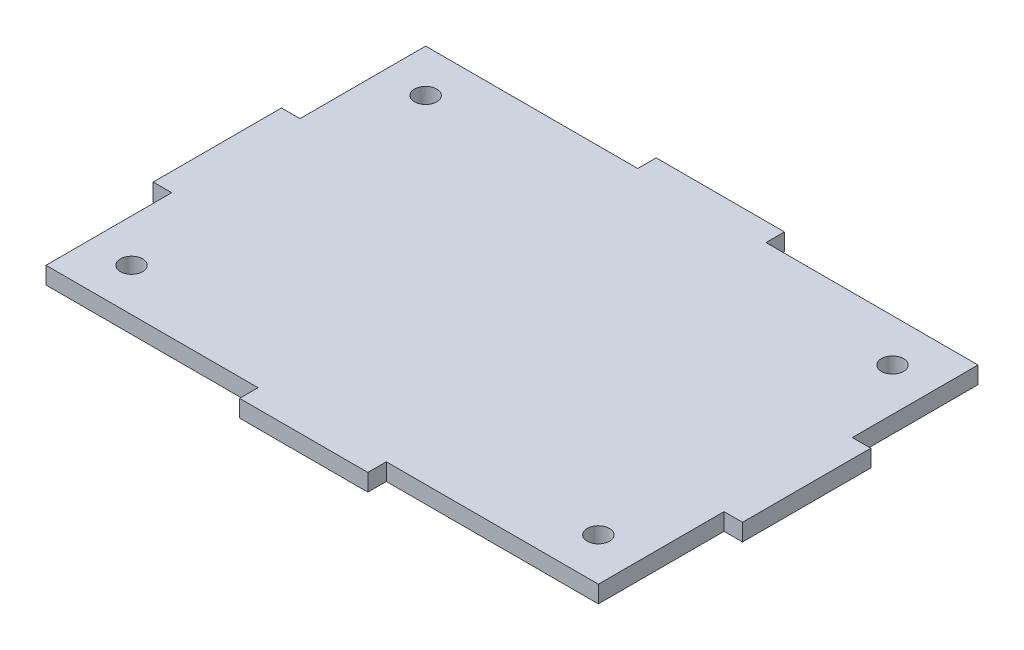
from build123d import *

# Parameters (mm, degrees)
SKETCH1_W           = 82.042
SKETCH1_H           = 56.388
SKETCH1_R           = 1.651
BOSS_EXTRUDE1_DEPTH = 2.54
SKETCH2_W           = 19.05
SKETCH2_H           = 2.7432
SKETCH2_W_2         = 2.7432
SKETCH2_H_2         = 19.05
BOSS_EXTRUDE2_DEPTH = 2.54


with BuildPart() as part:
    # Sketch1 → Boss-Extrude1 (new body)
    with BuildSketch(Plane(origin=(0, 0, 0), x_dir=(1, 0, 0), z_dir=(0, 1, 0))):
        Rectangle(SKETCH1_W, SKETCH1_H)
        with Locations((-34.671, 21.844)):
            Circle(SKETCH1_R, mode=Mode.SUBTRACT)
        with Locations((-34.671, -21.844)):
            Circle(SKETCH1_R, mode=Mode.SUBTRACT)
        with Locations((34.671, -21.844)):
            Circle(SKETCH1_R, mode=Mode.SUBTRACT)
        with Locations((34.671, 21.844)):
            Circle(SKETCH1_R, mode=Mode.SUBTRACT)
    extrude(amount=BOSS_EXTRUDE1_DEPTH)

    # Sketch2 → Boss-Extrude2 (add)
    with BuildSketch(Plane(origin=(0, 2.54, 0), x_dir=(1, 0, 0), z_dir=(0, 1, 0))):
        with Locations((0, 29.5656)):
            Rectangle(SKETCH2_W, SKETCH2_H)
        with Locations((0, -29.5656)):
            Rectangle(SKETCH2_W, SKETCH2_H)
        with Locations((42.3926, 0)):
            Rectangle(SKETCH2_W_2, SKETCH2_H_2)
        with Locations((-42.3926, 0)):
            Rectangle(SKETCH2_W_2, SKETCH2_H_2)
    extrude(amount=-BOSS_EXTRUDE2_DEPTH)


solid = part.part
